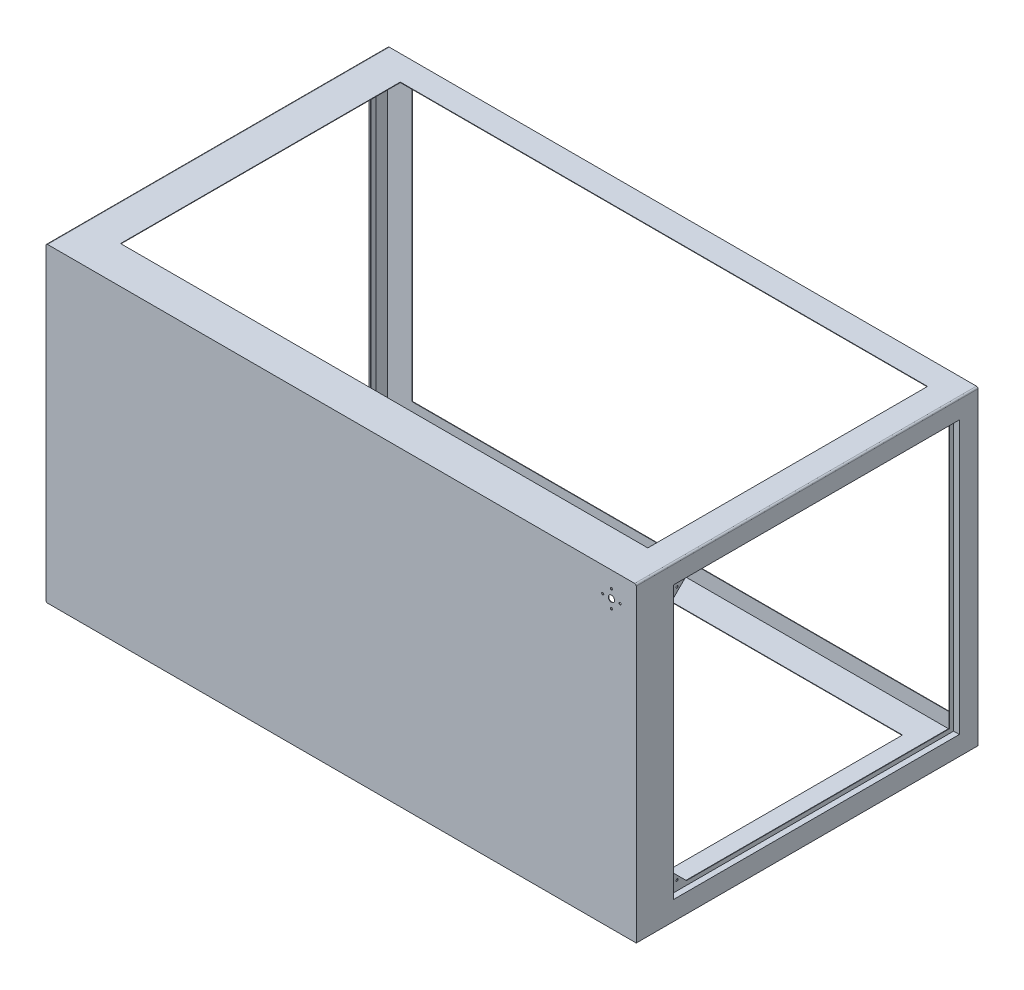
from build123d import *

# Parameters (mm, degrees)
SKETCH_1_W                     = 1900
SKETCH_1_H                     = 1000
EXTRUDE_1_DEPTH                = 550
SHELL_1_T                      = -1.5
SKETCH_2_W                     = 1897
SKETCH_2_H                     = 997
SKETCH_2_W_2                   = 1740
SKETCH_2_H_2                   = 900
EXTRUDE_2_DEPTH                = 1.5
FILLET_1_R                     = 5
SKETCH_9_R                     = 10
CUT_EXTRUDE_3_DEPTH            = 10
SKETCH_10_W                    = 1697.078401096
SKETCH_10_H                    = 900.514037569
CUT_EXTRUDE_4_DEPTH            = 20
SKETCH_18_W                    = 920
SKETCH_18_H                    = 877
CUT_EXTRUDE_5_DEPTH            = 1.5
SKETCH_34_W                    = 923
SKETCH_34_H                    = 880
SKETCH_34_W_2                  = 920
SKETCH_34_H_2                  = 877
EXTRUDE_6_DEPTH                = 17
SKETCH_35_W                    = 923
SKETCH_35_H                    = 880
SKETCH_35_W_2                  = 893
SKETCH_35_H_2                  = 850
EXTRUDE_7_DEPTH                = 1.5
EXTRUDE_8_DEPTH                = 1.5
HOLE_WIZARD_7_0_7_1_AT_2_COUNT = 2
HOLE_WIZARD_7_0_7_1_AT_2_PITCH = 817
EXTRUDE_9_DEPTH                = 897
EXTRUDE_10_DEPTH               = 897
PATTERN_CIRCULAR_2_COUNT       = 4
SKETCH_84_W                    = 1595.14155231
SKETCH_84_H                    = 886.893477963
CUT_EXTRUDE_22_DEPTH           = 10


with BuildPart() as part:
    # 草图1 → 凸台-拉伸1 (new body, symmetric)
    with BuildSketch(Plane.XY):
        Rectangle(SKETCH_1_W, SKETCH_1_H)
    extrude(amount=EXTRUDE_1_DEPTH, both=True)

    # 抽壳1
    shell_1_openings = [part.faces().sort_by_distance(p)[0] for p in [
        (0, 0, -550),
    ]]
    offset(amount=SHELL_1_T, openings=shell_1_openings, kind=Kind.INTERSECTION)

    # 圆角1
    fillet_1_edges = [part.edges().sort_by_distance(p)[0] for p in [
        (948.5, -498.5, -0.75),
        (-950, 500, 0),
        (950, 500, 0),
        (-950, -500, 0),
    ]]
    fillet(fillet_1_edges, radius=FILLET_1_R)

    # 草图9 → 切除-拉伸3 (cut)
    with BuildSketch(Plane.XY.offset(550)):
        with Locations((870, 420)):
            Circle(SKETCH_9_R)
    extrude(amount=-CUT_EXTRUDE_3_DEPTH, mode=Mode.SUBTRACT)

    # 草图10 → 切除-拉伸4 (cut)
    with BuildSketch(Plane(origin=(0, 500, 0), x_dir=(1, 0, 0), z_dir=(0, 1, 0))):
        with Locations((18.539200548, 20.257018785)):
            Rectangle(SKETCH_10_W, SKETCH_10_H)
    extrude(amount=-CUT_EXTRUDE_4_DEPTH, mode=Mode.SUBTRACT)

    # 草图18 → 切除-拉伸5 (cut)
    with BuildSketch(Plane.ZY.offset(950)):
        with Locations((-30, 0)):
            Rectangle(SKETCH_18_W, SKETCH_18_H)
    cut_extrude_5 = extrude(amount=-CUT_EXTRUDE_5_DEPTH, mode=Mode.SUBTRACT)

    # 草图34 → 凸台-拉伸6 (add)
    with BuildSketch(Plane(origin=(-948.5, 0, 0), x_dir=(0, 0, -1), z_dir=(1, 0, 0))):
        with Locations((30, 0)):
            Rectangle(SKETCH_34_W, SKETCH_34_H)
        with Locations((30, 0)):
            Rectangle(SKETCH_34_W_2, SKETCH_34_H_2, mode=Mode.SUBTRACT)
    extrude_6 = extrude(amount=EXTRUDE_6_DEPTH)

    # 草图35 → 凸台-拉伸7 (add)
    with BuildSketch(Plane(origin=(-931.5, 0, 0), x_dir=(0, 0, -1), z_dir=(1, 0, 0))):
        with Locations((30, 0)):
            Rectangle(SKETCH_35_W, SKETCH_35_H)
        with Locations((30, 0)):
            Rectangle(SKETCH_35_W_2, SKETCH_35_H_2, mode=Mode.SUBTRACT)
    extrude_7 = extrude(amount=EXTRUDE_7_DEPTH)

    # 草图36 → 凸台-拉伸8 (add)
    with BuildSketch(Plane.ZY.offset(931.5)):
        Polygon((370, 425), (416.5, 378.5), (416.5, 425), align=None)
        Polygon((416.5, -378.5), (370, -425), (416.5, -425), align=None)
    extrude_8 = extrude(amount=-EXTRUDE_8_DEPTH)

    # 草图37 → Ø7.0 (7) 直径孔1 (revolve, cut)
    with BuildSketch(Plane(origin=(-931.5, 408.5, 400), x_dir=(0, 0, 1), z_dir=(0, 1, 0))):
        Polygon((0, 0), (0, 3.603012167), (3.5, 1.5), (3.5, 0), align=None)
    hole_wizard_7_0_7_1 = revolve(axis=Axis((-937.85, 408.5, 400), (1, 0, 0)), mode=Mode.SUBTRACT)

    # Ø7.0 (7) 直径孔1 at 2: Ø7.0 (7) 直径孔1 ×2
    with Locations(*[(0, -i * HOLE_WIZARD_7_0_7_1_AT_2_PITCH, 0) for i in range(1, HOLE_WIZARD_7_0_7_1_AT_2_COUNT)]):
        add(hole_wizard_7_0_7_1, mode=Mode.SUBTRACT)

    # 镜向4: 切除-拉伸5 across plane
    add(cut_extrude_5.mirror(Plane(origin=(0, 0, 0), x_dir=(0, 0, 1), z_dir=(1, 0, 0))), mode=Mode.SUBTRACT)

    # 镜向7: 凸台-拉伸6 across plane
    add(extrude_6.mirror(Plane(origin=(0, 0, 0), x_dir=(0, 0, 1), z_dir=(1, 0, 0))))

    # 镜向8: 凸台-拉伸7 across plane
    add(extrude_7.mirror(Plane(origin=(0, 0, 0), x_dir=(0, 0, 1), z_dir=(1, 0, 0))))

    # 镜向10: 凸台-拉伸8 across plane
    add(extrude_8.mirror(Plane(origin=(0, 0, 0), x_dir=(0, 0, 1), z_dir=(1, 0, 0))))

    # 镜向11: Ø7.0 (7) 直径孔1 across plane
    add(hole_wizard_7_0_7_1.mirror(Plane(origin=(0, 0, 0), x_dir=(0, 0, 1), z_dir=(1, 0, 0))), mode=Mode.SUBTRACT)

    # 镜向11 copy 1 sketch → 镜向11 copy 1 (revolve, cut)
    with BuildSketch(Plane(origin=(931.5, -408.5, 400), x_dir=(0, 0, 1), z_dir=(0, 1, 0))):
        Polygon((0, 0), (0, -3.603012167), (3.5, -1.5), (3.5, 0), align=None)
    revolve(axis=Axis((937.85, -408.5, 400), (1, 0, 0)), mode=Mode.SUBTRACT)

    # 草图53 → 凸台-拉伸9 (add)
    with BuildSketch(Plane(origin=(0, 0, 548.5), x_dir=(-1, 0, 0), z_dir=(0, 0, -1))):
        with BuildLine():
            Line((850, -445), (850, -453))
            ThreePointArc((850, -453), (850.585786438, -454.414213562), (852, -455))
            Line((852, -455), (872, -455))
            ThreePointArc((872, -455), (873.414213562, -454.414213562), (874, -453))
            Line((874, -453), (874, -445))
            Line((874, -445), (872.5, -445))
            Line((872.5, -445), (872.5, -452))
            ThreePointArc((872.5, -452), (872.060660172, -453.060660172), (871, -453.5))
            Line((871, -453.5), (853, -453.5))
            ThreePointArc((853, -453.5), (851.939339828, -453.060660172), (851.5, -452))
            Line((851.5, -452), (851.5, -445))
            Line((851.5, -445), (850, -445))
        make_face()
    extrude(amount=EXTRUDE_9_DEPTH)

    # 草图54 → 凸台-拉伸10 (add)
    with BuildSketch(Plane(origin=(0, 0, 548.5), x_dir=(-1, 0, 0), z_dir=(0, 0, -1))):
        with BuildLine():
            Line((927, -399), (927, -417))
            ThreePointArc((927, -417), (926.414213562, -418.414213562), (925, -419))
            Line((925, -419), (874, -419))
            ThreePointArc((874, -419), (872.585786438, -418.414213562), (872, -417))
            Line((872, -417), (872, -399))
            Line((872, -399), (873.5, -399))
            Line((873.5, -399), (873.5, -416))
            ThreePointArc((873.5, -416), (873.939339828, -417.060660172), (875, -417.5))
            Line((875, -417.5), (924, -417.5))
            ThreePointArc((924, -417.5), (925.060660172, -417.060660172), (925.5, -416))
            Line((925.5, -416), (925.5, -399))
            Line((925.5, -399), (927, -399))
        make_face()
    extrude(amount=EXTRUDE_10_DEPTH)

    # 草图56 → Ø7.0 (7) 直径孔3 (revolve, cut)
    with BuildSketch(Plane(origin=(870, 392, 550), x_dir=(0, -1, 0), z_dir=(1, 0, 0))):
        Polygon((0, 0), (0, 4.103012167), (3.5, 2), (3.5, 0), align=None)
    hole_wizard_7_0_7_3 = revolve(axis=Axis((870, 392, 556.35), (0, 0, -1)), mode=Mode.SUBTRACT)

    # 阵列(圆周)2: Ø7.0 (7) 直径孔3 ×4 about axis
    pattern_circular_2_axis = Axis((870, 420, 0), (0, 0, 1))
    for i in range(1, PATTERN_CIRCULAR_2_COUNT):
        add(hole_wizard_7_0_7_3.rotate(pattern_circular_2_axis, i * 360 / PATTERN_CIRCULAR_2_COUNT), mode=Mode.SUBTRACT)

    # 草图84 → 切除-拉伸22 (cut)
    with BuildSketch(Plane.XZ.offset(500)):
        with Locations((2.429223845, -13.446738982)):
            Rectangle(SKETCH_84_W, SKETCH_84_H)
    extrude(amount=-CUT_EXTRUDE_22_DEPTH, mode=Mode.SUBTRACT)


with BuildPart() as body_2:
    # 草图2 → 凸台-拉伸2 (new body)
    with BuildSketch(Plane(origin=(0, 0, -550), x_dir=(-1, 0, 0), z_dir=(0, 0, -1))):
        Rectangle(SKETCH_2_W, SKETCH_2_H)
        Rectangle(SKETCH_2_W_2, SKETCH_2_H_2, mode=Mode.SUBTRACT)
    extrude(amount=-EXTRUDE_2_DEPTH)


solid = Compound([part.part, body_2.part])
